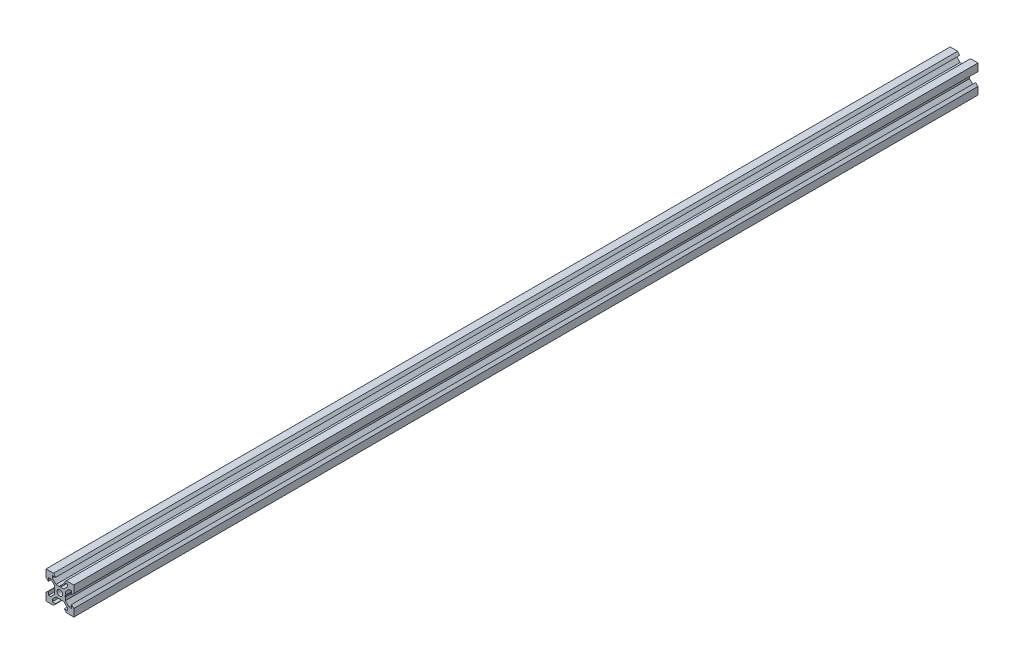
from build123d import *

# Parameters (mm, degrees)
SKETCH1_R           = 2
BOSS_EXTRUDE1_DEPTH = 325


with BuildPart() as part:
    # Sketch1 → Boss-Extrude1 (new body, symmetric)
    with BuildSketch(Plane.XY):
        Polygon((10, 10), (10, 4.610379336), (8.2, 3.1), (8.2, 5.5), (6.560660172, 5.5), (3.9, 2.839339828), (3.9, 0.519615242), (3.6, 0), (3.9, -0.519615242), (3.9, -2.839339828), (6.560660172, -5.5), (8.2, -5.5), (8.2, -3.1), (10, -4.610379336), (10, -10), (4.610379336, -10), (3.1, -8.2), (5.5, -8.2), (5.5, -6.560660172), (2.839339828, -3.9), (0.519615242, -3.9), (0, -3.6), (-0.519615242, -3.9), (-2.839339828, -3.9), (-5.5, -6.560660172), (-5.5, -8.2), (-3.1, -8.2), (-4.610379336, -10), (-10, -10), (-10, -4.610379336), (-8.2, -3.1), (-8.2, -5.5), (-6.560660172, -5.5), (-3.9, -2.839339828), (-3.9, -0.519615242), (-3.6, 0), (-3.9, 0.519615242), (-3.9, 2.839339828), (-6.560660172, 5.5), (-8.2, 5.5), (-8.2, 3.1), (-10, 4.610379336), (-10, 10), (-4.610379336, 10), (-3.1, 8.2), (-5.5, 8.2), (-5.5, 6.560660172), (-2.839339828, 3.9), (-0.519615242, 3.9), (0, 3.6), (0.519615242, 3.9), (2.839339828, 3.9), (5.5, 6.560660172), (5.5, 8.2), (3.1, 8.2), (4.610379336, 10), align=None)
        Circle(SKETCH1_R, mode=Mode.SUBTRACT)
    extrude(amount=BOSS_EXTRUDE1_DEPTH, both=True)


solid = part.part
